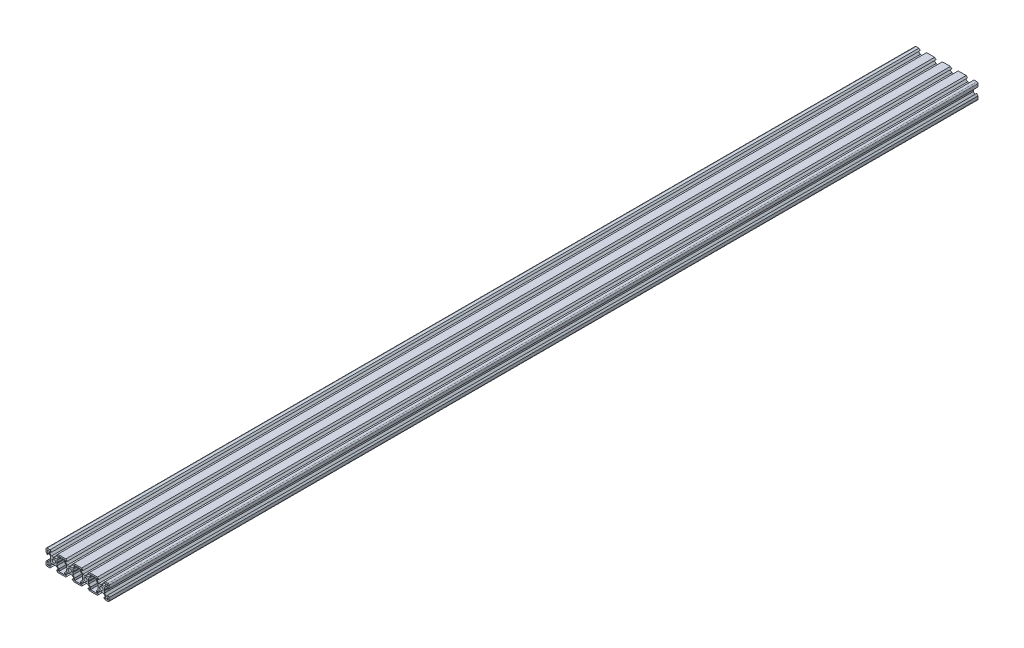
from build123d import *

# Parameters (mm, degrees)
SKETCH1_R           = 2.1
BOSS_EXTRUDE1_DEPTH = 1100


with BuildPart() as part:
    # Sketch1 → Boss-Extrude1 (new body)
    with BuildSketch(Plane.XY):
        with BuildLine():
            Line((4.9, -10), (15.097742088, -10))
            Line((15.097742088, -10), (16.897742088, -8.2))
            Line((16.897742088, -8.2), (14.597742088, -8.2))
            Line((14.597742088, -8.2), (14.597742088, -6.3))
            Line((14.597742088, -6.3), (16.897742088, -4))
            Line((16.897742088, -4), (19.497742088, -4))
            ThreePointArc((19.497742088, -4), (19.997742088, -3.5), (20.497742088, -4))
            Line((20.497742088, -4), (23.097742088, -4))
            Line((23.097742088, -4), (25.397742088, -6.3))
            Line((25.397742088, -6.3), (25.397742088, -8.2))
            Line((25.397742088, -8.2), (23.097742088, -8.2))
            Line((23.097742088, -8.2), (24.897742088, -10))
            Line((24.897742088, -10), (35.1, -10))
            Line((35.1, -10), (36.9, -8.2))
            Line((36.9, -8.2), (34.6, -8.2))
            Line((34.6, -8.2), (34.6, -6.3))
            Line((34.6, -6.3), (36.9, -4))
            Line((36.9, -4), (39.5, -4))
            ThreePointArc((39.5, -4), (40, -3.5), (40.5, -4))
            Line((40.5, -4), (43.1, -4))
            Line((43.1, -4), (45.4, -6.3))
            Line((45.4, -6.3), (45.4, -8.2))
            Line((45.4, -8.2), (43.1, -8.2))
            Line((43.1, -8.2), (44.9, -10))
            Line((44.9, -10), (55.097742088, -10))
            Line((55.097742088, -10), (56.897742088, -8.2))
            Line((56.897742088, -8.2), (54.597742088, -8.2))
            Line((54.597742088, -8.2), (54.597742088, -6.3))
            Line((54.597742088, -6.3), (56.897742088, -4))
            Line((56.897742088, -4), (59.497742088, -4))
            ThreePointArc((59.497742088, -4), (59.997742088, -3.5), (60.497742088, -4))
            Line((60.497742088, -4), (63.097742088, -4))
            Line((63.097742088, -4), (65.397742088, -6.3))
            Line((65.397742088, -6.3), (65.397742088, -8.2))
            Line((65.397742088, -8.2), (63.097742088, -8.2))
            Line((63.097742088, -8.2), (64.897742088, -10))
            Line((64.897742088, -10), (68.498871044, -10))
            ThreePointArc((68.498871044, -10), (69.559531216, -9.560660172), (69.998871044, -8.5))
            Line((69.998871044, -8.5), (69.998871044, -4.88759823))
            Line((69.998871044, -4.88759823), (68.211272814, -3.1))
            Line((68.211272814, -3.1), (68.211272814, -5.4))
            Line((68.211272814, -5.4), (66.311272814, -5.4))
            Line((66.311272814, -5.4), (64.011272814, -3.1))
            Line((64.011272814, -3.1), (64.011272814, -0.5))
            ThreePointArc((64.011272814, -0.5), (63.511272814, 0), (64.011272814, 0.5))
            Line((64.011272814, 0.5), (64.011272814, 3.1))
            Line((64.011272814, 3.1), (66.311272814, 5.4))
            Line((66.311272814, 5.4), (68.211272814, 5.4))
            Line((68.211272814, 5.4), (68.198871044, 3.1))
            Line((68.198871044, 3.1), (69.998871044, 4.9))
            Line((69.998871044, 4.9), (69.998871044, 8.5))
            ThreePointArc((69.998871044, 8.5), (69.559531216, 9.560660172), (68.498871044, 10))
            Line((68.498871044, 10), (64.897742088, 10))
            Line((64.897742088, 10), (63.097742088, 8.2))
            Line((63.097742088, 8.2), (65.397742088, 8.2))
            Line((65.397742088, 8.2), (65.397742088, 6.3))
            Line((65.397742088, 6.3), (63.097742088, 4))
            Line((63.097742088, 4), (60.497742088, 4))
            ThreePointArc((60.497742088, 4), (59.997742088, 3.5), (59.497742088, 4))
            Line((59.497742088, 4), (56.897742088, 4))
            Line((56.897742088, 4), (54.597742088, 6.3))
            Line((54.597742088, 6.3), (54.597742088, 8.2))
            Line((54.597742088, 8.2), (56.897742088, 8.2))
            Line((56.897742088, 8.2), (55.097742088, 10))
            Line((55.097742088, 10), (44.9, 10))
            Line((44.9, 10), (43.1, 8.2))
            Line((43.1, 8.2), (45.4, 8.2))
            Line((45.4, 8.2), (45.4, 6.3))
            Line((45.4, 6.3), (43.1, 4))
            Line((43.1, 4), (40.5, 4))
            ThreePointArc((40.5, 4), (40, 3.5), (39.5, 4))
            Line((39.5, 4), (36.9, 4))
            Line((36.9, 4), (34.6, 6.3))
            Line((34.6, 6.3), (34.6, 8.2))
            Line((34.6, 8.2), (36.9, 8.2))
            Line((36.9, 8.2), (35.1, 10))
            Line((35.1, 10), (24.897742088, 10))
            Line((24.897742088, 10), (23.097742088, 8.2))
            Line((23.097742088, 8.2), (25.397742088, 8.2))
            Line((25.397742088, 8.2), (25.397742088, 6.3))
            Line((25.397742088, 6.3), (23.097742088, 4))
            Line((23.097742088, 4), (20.497742088, 4))
            ThreePointArc((20.497742088, 4), (19.997742088, 3.5), (19.497742088, 4))
            Line((19.497742088, 4), (16.897742088, 4))
            Line((16.897742088, 4), (14.597742088, 6.3))
            Line((14.597742088, 6.3), (14.597742088, 8.2))
            Line((14.597742088, 8.2), (16.897742088, 8.2))
            Line((16.897742088, 8.2), (15.097742088, 10))
            Line((15.097742088, 10), (4.9, 10))
            Line((4.9, 10), (3.1, 8.2))
            Line((3.1, 8.2), (5.4, 8.2))
            Line((5.4, 8.2), (5.4, 6.3))
            Line((5.4, 6.3), (3.1, 4))
            Line((3.1, 4), (0.5, 4))
            ThreePointArc((0.5, 4), (0, 3.5), (-0.5, 4))
            Line((-0.5, 4), (-3.1, 4))
            Line((-3.1, 4), (-5.4, 6.3))
            Line((-5.4, 6.3), (-5.4, 8.2))
            Line((-5.4, 8.2), (-3.1, 8.2))
            Line((-3.1, 8.2), (-4.9, 10))
            Line((-4.9, 10), (-8.501128956, 10))
            ThreePointArc((-8.501128956, 10), (-9.561789128, 9.560660172), (-10.001128956, 8.5))
            Line((-10.001128956, 8.5), (-10.001128956, 4.9))
            Line((-10.001128956, 4.9), (-8.201128956, 3.1))
            Line((-8.201128956, 3.1), (-8.213530726, 5.4))
            Line((-8.213530726, 5.4), (-6.313530726, 5.4))
            Line((-6.313530726, 5.4), (-4.013530726, 3.1))
            Line((-4.013530726, 3.1), (-4.013530726, 0.5))
            ThreePointArc((-4.013530726, 0.5), (-3.513530726, 0), (-4.013530726, -0.5))
            Line((-4.013530726, -0.5), (-4.013530726, -3.1))
            Line((-4.013530726, -3.1), (-6.313530726, -5.4))
            Line((-6.313530726, -5.4), (-8.213530726, -5.4))
            Line((-8.213530726, -5.4), (-8.213530726, -3.1))
            Line((-8.213530726, -3.1), (-10.001128956, -4.88759823))
            Line((-10.001128956, -4.88759823), (-10.001128956, -8.5))
            ThreePointArc((-10.001128956, -8.5), (-9.561789128, -9.560660172), (-8.501128956, -10))
            Line((-8.501128956, -10), (-4.9, -10))
            Line((-4.9, -10), (-3.1, -8.2))
            Line((-3.1, -8.2), (-5.4, -8.2))
            Line((-5.4, -8.2), (-5.4, -6.3))
            Line((-5.4, -6.3), (-3.1, -4))
            Line((-3.1, -4), (-0.5, -4))
            ThreePointArc((-0.5, -4), (0, -3.5), (0.5, -4))
            Line((0.5, -4), (3.1, -4))
            Line((3.1, -4), (5.4, -6.3))
            Line((5.4, -6.3), (5.4, -8.2))
            Line((5.4, -8.2), (3.1, -8.2))
            Line((3.1, -8.2), (4.9, -10))
        make_face()
        Circle(SKETCH1_R, mode=Mode.SUBTRACT)
        with Locations((40, 0)):
            Circle(SKETCH1_R, mode=Mode.SUBTRACT)
        with Locations((19.997742088, 0)):
            Circle(SKETCH1_R, mode=Mode.SUBTRACT)
        with Locations((59.997742088, 0)):
            Circle(SKETCH1_R, mode=Mode.SUBTRACT)
        with BuildLine():
            Line((3.998871044, 0.5), (3.998871044, 3.1))
            Line((3.998871044, 3.1), (6.298871044, 5.4))
            Line((6.298871044, 5.4), (6.298871044, 8.2))
            Line((6.298871044, 8.2), (13.698871044, 8.2))
            Line((13.698871044, 8.2), (13.698871044, 5.4))
            Line((13.698871044, 5.4), (15.998871044, 3.1))
            Line((15.998871044, 3.1), (15.998871044, 0.5))
            ThreePointArc((15.998871044, 0.5), (16.498871044, 0), (15.998871044, -0.5))
            Line((15.998871044, -0.5), (15.998871044, -3.1))
            Line((15.998871044, -3.1), (13.698871044, -5.4))
            Line((13.698871044, -5.4), (13.698871044, -8.2))
            Line((13.698871044, -8.2), (6.298871044, -8.2))
            Line((6.298871044, -8.2), (6.298871044, -5.4))
            Line((6.298871044, -5.4), (3.998871044, -3.1))
            Line((3.998871044, -3.1), (3.998871044, -0.5))
            ThreePointArc((3.998871044, -0.5), (3.498871044, 0), (3.998871044, 0.5))
        make_face(mode=Mode.SUBTRACT)
        with BuildLine():
            Line((26.311272814, -5.4), (26.311272814, -8.2))
            Line((26.311272814, -8.2), (33.686469274, -8.2))
            Line((33.686469274, -8.2), (33.686469274, -5.4))
            Line((33.686469274, -5.4), (35.986469274, -3.1))
            Line((35.986469274, -3.1), (35.986469274, -0.5))
            ThreePointArc((35.986469274, -0.5), (36.486469274, 0), (35.986469274, 0.5))
            Line((35.986469274, 0.5), (35.986469274, 3.1))
            Line((35.986469274, 3.1), (33.686469274, 5.4))
            Line((33.686469274, 5.4), (33.686469274, 8.2))
            Line((33.686469274, 8.2), (26.311272814, 8.2))
            Line((26.311272814, 8.2), (26.311272814, 5.4))
            Line((26.311272814, 5.4), (24.011272814, 3.1))
            Line((24.011272814, 3.1), (24.011272814, 0.5))
            ThreePointArc((24.011272814, 0.5), (23.511272814, 0), (24.011272814, -0.5))
            Line((24.011272814, -0.5), (24.011272814, -3.1))
            Line((24.011272814, -3.1), (26.311272814, -5.4))
        make_face(mode=Mode.SUBTRACT)
        with BuildLine():
            Line((-8.201128956, 7.07322093), (-8.201128956, 7.7))
            ThreePointArc((-8.201128956, 7.7), (-8.054682347, 8.053553391), (-7.701128956, 8.2))
            Line((-7.701128956, 8.2), (-7.07381417, 8.2))
            ThreePointArc((-7.07381417, 8.2), (-6.84282968, 8.045635587), (-6.897091472, 7.773169324))
            Line((-6.897091472, 7.773169324), (-7.774406258, 6.896390254))
            ThreePointArc((-7.774406258, 6.896390254), (-8.046835083, 6.842265659), (-8.201128956, 7.07322093))
        make_face(mode=Mode.SUBTRACT)
        with BuildLine():
            Line((-6.897091472, -7.773169324), (-7.774406258, -6.896390254))
            ThreePointArc((-7.774406258, -6.896390254), (-8.046835083, -6.842265659), (-8.201128956, -7.07322093))
            Line((-8.201128956, -7.07322093), (-8.201128956, -7.7))
            ThreePointArc((-8.201128956, -7.7), (-8.054682347, -8.053553391), (-7.701128956, -8.2))
            Line((-7.701128956, -8.2), (-7.07381417, -8.2))
            ThreePointArc((-7.07381417, -8.2), (-6.84282968, -8.045635587), (-6.897091472, -7.773169324))
        make_face(mode=Mode.SUBTRACT)
        with BuildLine():
            Line((43.998871044, 0.5), (43.998871044, 3.1))
            Line((43.998871044, 3.1), (46.298871044, 5.4))
            Line((46.298871044, 5.4), (46.298871044, 8.2))
            Line((46.298871044, 8.2), (53.698871044, 8.2))
            Line((53.698871044, 8.2), (53.698871044, 5.4))
            Line((53.698871044, 5.4), (55.998871044, 3.1))
            Line((55.998871044, 3.1), (55.998871044, 0.5))
            ThreePointArc((55.998871044, 0.5), (56.498871044, 0), (55.998871044, -0.5))
            Line((55.998871044, -0.5), (55.998871044, -3.1))
            Line((55.998871044, -3.1), (53.698871044, -5.4))
            Line((53.698871044, -5.4), (53.698871044, -8.2))
            Line((53.698871044, -8.2), (46.298871044, -8.2))
            Line((46.298871044, -8.2), (46.298871044, -5.4))
            Line((46.298871044, -5.4), (43.998871044, -3.1))
            Line((43.998871044, -3.1), (43.998871044, -0.5))
            ThreePointArc((43.998871044, -0.5), (43.498871044, 0), (43.998871044, 0.5))
        make_face(mode=Mode.SUBTRACT)
        with BuildLine():
            Line((68.198871044, -7.07322093), (68.198871044, -7.7))
            ThreePointArc((68.198871044, -7.7), (68.052424435, -8.053553391), (67.698871044, -8.2))
            Line((67.698871044, -8.2), (67.071556258, -8.2))
            ThreePointArc((67.071556258, -8.2), (66.840571768, -8.045635587), (66.89483356, -7.773169324))
            Line((66.89483356, -7.773169324), (67.772148346, -6.896390254))
            ThreePointArc((67.772148346, -6.896390254), (68.044577171, -6.842265659), (68.198871044, -7.07322093))
        make_face(mode=Mode.SUBTRACT)
        with BuildLine():
            Line((66.89483356, 7.773169324), (67.772148346, 6.896390254))
            ThreePointArc((67.772148346, 6.896390254), (68.044577171, 6.842265659), (68.198871044, 7.07322093))
            Line((68.198871044, 7.07322093), (68.198871044, 7.7))
            ThreePointArc((68.198871044, 7.7), (68.052424435, 8.053553391), (67.698871044, 8.2))
            Line((67.698871044, 8.2), (67.071556258, 8.2))
            ThreePointArc((67.071556258, 8.2), (66.840571768, 8.045635587), (66.89483356, 7.773169324))
        make_face(mode=Mode.SUBTRACT)
    extrude(amount=BOSS_EXTRUDE1_DEPTH)


solid = part.part
